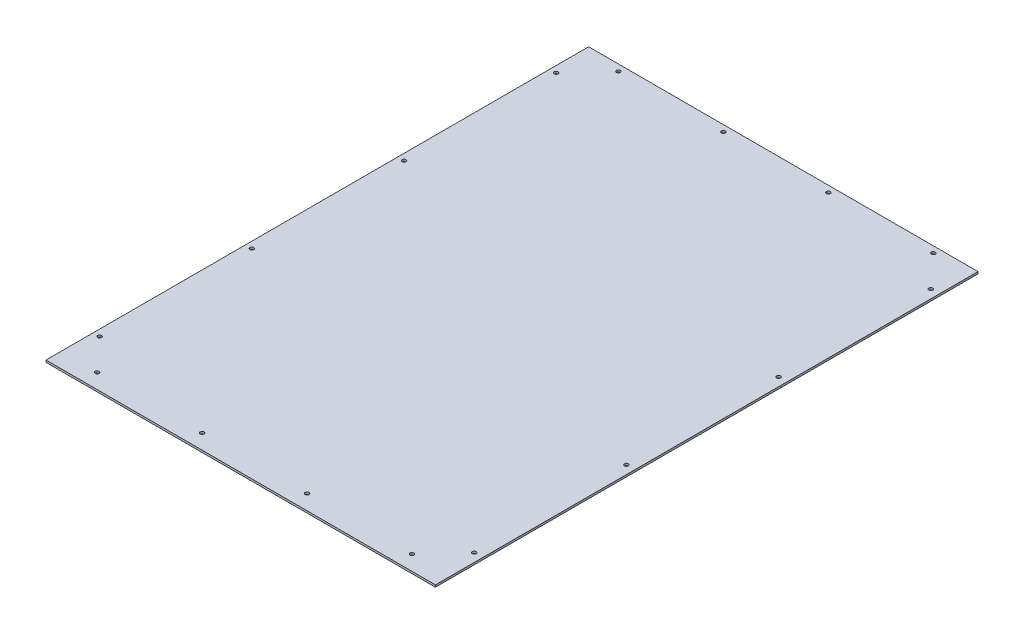
from build123d import *

# Parameters (mm, degrees)
SKETCH1_W            = 581.1266
SKETCH1_H            = 809.7266
REARSHEET_DEPTH      = 3.0734
SKETCH2_R            = 2.8956
TOPBOTTOMHOLES_DEPTH = 4.0734
SKETCH3_R            = 2.8956
VERTHOLES_DEPTH      = 4.0734
LPATTERN1_COUNT      = 4
LPATTERN1_PITCH      = 156.633333333
LPATTERN2_COUNT      = 4
LPATTERN2_PITCH      = 227.084466667
CUT_EXTRUDE1_DEPTH   = 2.54


with BuildPart() as part:
    # Sketch1 → RearSheet (new body)
    with BuildSketch(Plane(origin=(0, 0, 0), x_dir=(1, 0, 0), z_dir=(0, 1, 0))):
        with Locations((290.5633, 404.8633)):
            Rectangle(SKETCH1_W, SKETCH1_H)
    extrude(amount=REARSHEET_DEPTH)

    # Sketch2 → TopBottomHoles (cut, through all)
    with BuildSketch(Plane(origin=(0, 3.0734, 0), x_dir=(1, 0, 0), z_dir=(0, 1, 0))):
        with Locations((54.0766, 800.2016)):
            Circle(SKETCH2_R)
        with Locations((54.0766, 22.225)):
            Circle(SKETCH2_R)
    topbottomholes = extrude(amount=-TOPBOTTOMHOLES_DEPTH, mode=Mode.SUBTRACT)

    # Sketch3 → VertHoles (cut, through all)
    with BuildSketch(Plane(origin=(0, 3.0734, 0), x_dir=(1, 0, 0), z_dir=(0, 1, 0))):
        with Locations((9.525, 751.84)):
            Circle(SKETCH3_R)
        with Locations((568.5282, 751.84)):
            Circle(SKETCH3_R)
    vertholes = extrude(amount=-VERTHOLES_DEPTH, mode=Mode.SUBTRACT)

    # LPattern1: TopBottomHoles ×4
    with Locations(*[(i * LPATTERN1_PITCH, 0, 0) for i in range(1, LPATTERN1_COUNT)]):
        add(topbottomholes, mode=Mode.SUBTRACT)

    # LPattern2: VertHoles ×4
    with Locations(*[(0, 0, i * LPATTERN2_PITCH) for i in range(1, LPATTERN2_COUNT)]):
        add(vertholes, mode=Mode.SUBTRACT)

    # Sketch4 → Cut-Extrude1 (cut)
    with BuildSketch(Plane.XZ):
        Polygon((10.033, -19.3294), (9.017, -19.3294), (9.017, -20.5994), (8.509, -20.5994), (9.525, -21.8694), (10.541, -20.5994), (10.033, -20.5994), align=None)
    extrude(amount=-CUT_EXTRUDE1_DEPTH, mode=Mode.SUBTRACT)


solid = part.part
